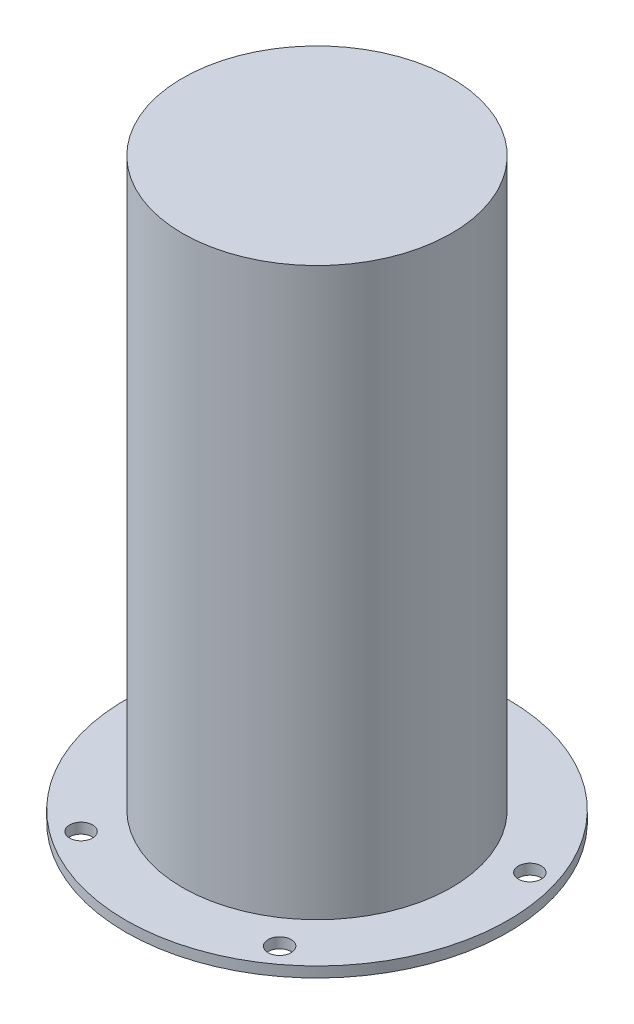
from build123d import *

# Parameters (mm, degrees)
SKETCH1_R           = 55
SKETCH1_R_2         = 37.5
SKETCH1_R_3         = 3.3
BOSS_EXTRUDE1_DEPTH = 3
SKETCH2_R           = 3.175
SKETCH3_R           = 38.7
SKETCH3_R_2         = 37.5
BOSS_EXTRUDE2_DEPTH = 160
SKETCH4_R           = 38.7
BOSS_EXTRUDE3_DEPTH = 3


with BuildPart() as part:
    # Sketch1 → Boss-Extrude1 (new body)
    with BuildSketch(Plane(origin=(0, 0, 0), x_dir=(1, 0, 0), z_dir=(0, 1, 0))):
        Circle(SKETCH1_R)
        Circle(SKETCH1_R_2, mode=Mode.SUBTRACT)
        with Locations((0, 48.6)):
            Circle(SKETCH1_R_3, mode=Mode.SUBTRACT)
        with Locations((46.221346692, 15.018225927)):
            Circle(SKETCH1_R_3, mode=Mode.SUBTRACT)
        with Locations((28.566363261, -39.318225927)):
            Circle(SKETCH1_R_3, mode=Mode.SUBTRACT)
        with Locations((-28.566363261, -39.318225927)):
            Circle(SKETCH1_R_3, mode=Mode.SUBTRACT)
        with Locations((-46.221346692, 15.018225927)):
            Circle(SKETCH1_R_3, mode=Mode.SUBTRACT)
    extrude(amount=BOSS_EXTRUDE1_DEPTH)

    # Sketch2 → Cut-Revolve1 (revolve, cut)
    with BuildSketch(Plane.XY):
        with Locations((40.825, -1.775)):
            Circle(SKETCH2_R)
    revolve(axis=Axis((0, 0, 0), (0, 1, 0)), mode=Mode.SUBTRACT)

    # Sketch3 → Boss-Extrude2 (add)
    with BuildSketch(Plane(origin=(0, 3, 0), x_dir=(1, 0, 0), z_dir=(0, 1, 0))):
        Circle(SKETCH3_R)
        Circle(SKETCH3_R_2, mode=Mode.SUBTRACT)
    extrude(amount=BOSS_EXTRUDE2_DEPTH)

    # Sketch4 → Boss-Extrude3 (add)
    with BuildSketch(Plane(origin=(0, 163, 0), x_dir=(1, 0, 0), z_dir=(0, 1, 0))):
        Circle(SKETCH4_R)
    extrude(amount=BOSS_EXTRUDE3_DEPTH)


solid = part.part
